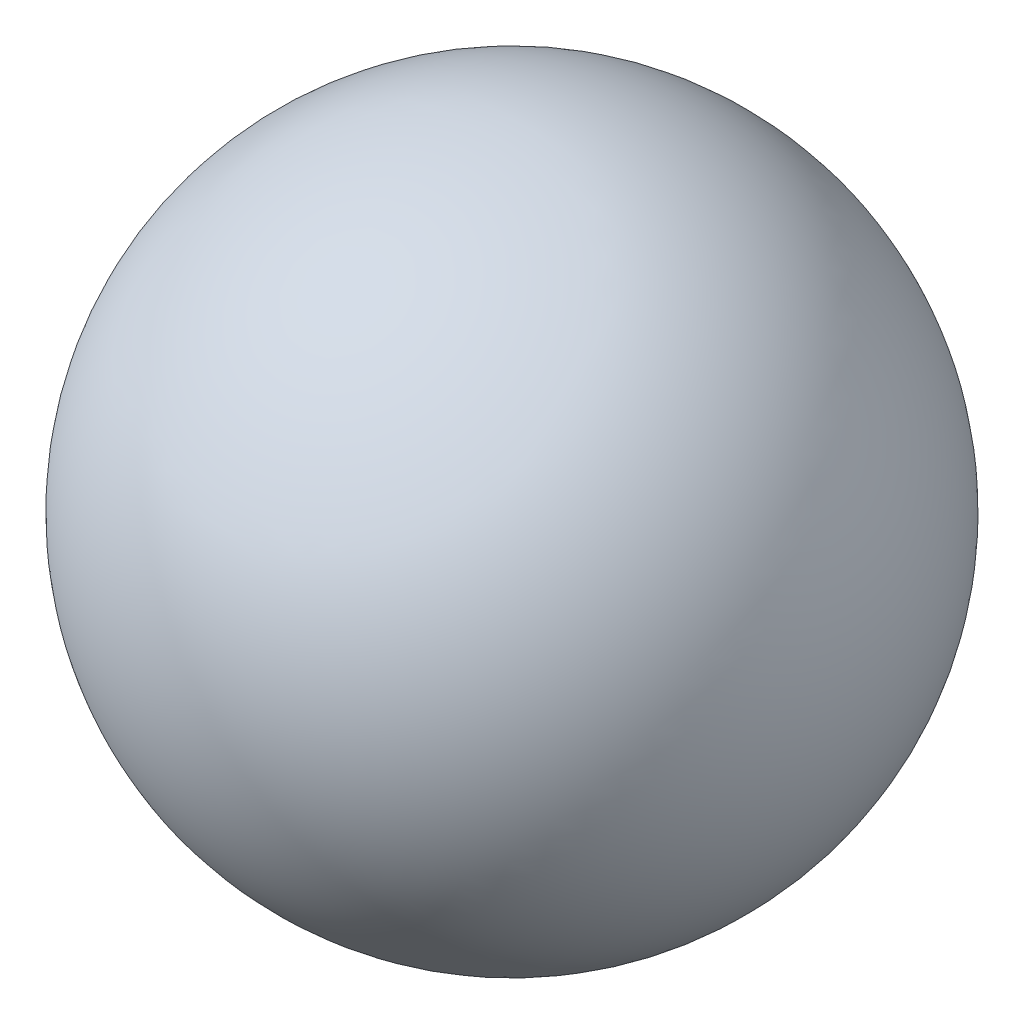
from build123d import *


with BuildPart() as part:
    # Sketch1 → Revolve1 (revolve)
    with BuildSketch(Plane(origin=(0, 0, 0), x_dir=(1, 0, 0), z_dir=(0, 1, 0))):
        with BuildLine():
            Line((0, 9.525), (0, -9.525))
            ThreePointArc((0, -9.525), (9.525, 0), (0, 9.525))
        make_face()
    revolve(axis=Axis((0, 0, -9.525), (0, 0, 1)))


solid = part.part
